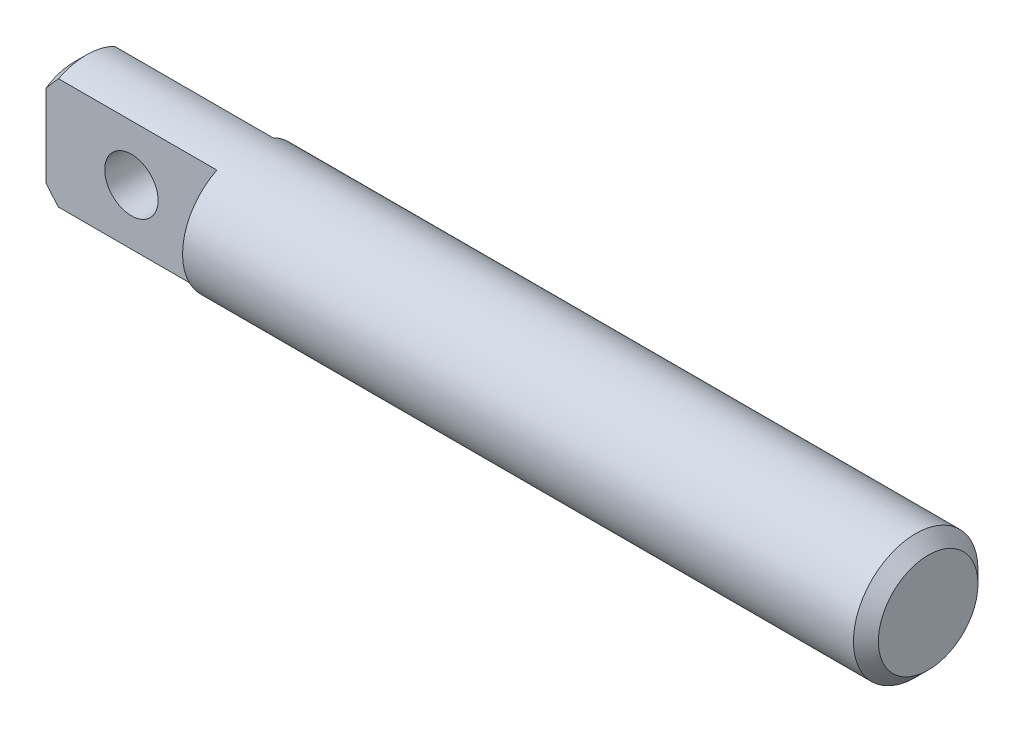
from build123d import *

# Parameters (mm, degrees)
SKETCH2_R           = 2.778125
EXTRUDE1_DEPTH      = 19.05
EXTRUDE1_DEPTH_BACK = 19.05
CHAMFER1_SIZE       = 0.555625
CUT_EXTRUDE1_DEPTH  = 7.62
SKETCH5_R           = 1.190625
CUT_EXTRUDE2_DEPTH  = 5.02828125


with BuildPart() as part:
    # Sketch2 → Extrude1 (new body, two sides)
    with BuildSketch(Plane(origin=(0, 0, 0), x_dir=(0, 0, -1), z_dir=(1, 0, 0))) as extrude1_sk:
        Circle(SKETCH2_R)
    extrude(amount=EXTRUDE1_DEPTH)
    extrude(extrude1_sk.sketch, amount=-EXTRUDE1_DEPTH_BACK)

    # Chamfer1
    chamfer1_edges = [part.edges().sort_by_distance(p)[0] for p in [
        (-19.05, 0, 2.778125),
        (19.05, 0, 2.778125),
    ]]
    chamfer(chamfer1_edges, length=CHAMFER1_SIZE)

    # Sketch3 → Cut-Extrude1 (cut)
    with BuildSketch(Plane.ZY.offset(19.05)):
        with BuildLine():
            Line((-3.175, 3.175), (-3.175, -3.175))
            Line((-3.175, -3.175), (-1.25015625, -3.175))
            Line((-1.25015625, -3.175), (-1.25015625, -1.837556965))
            ThreePointArc((-1.25015625, -1.837556965), (-2.2225, 0), (-1.25015625, 1.837556965))
            Line((-1.25015625, 1.837556965), (-1.25015625, 3.175))
            Line((-1.25015625, 3.175), (-3.175, 3.175))
        make_face()
        with BuildLine():
            Line((1.25015625, -1.837556965), (1.25015625, -3.175))
            Line((1.25015625, -3.175), (3.175, -3.175))
            Line((3.175, -3.175), (3.175, 3.175))
            Line((3.175, 3.175), (1.25015625, 3.175))
            Line((1.25015625, 3.175), (1.25015625, 1.837556965))
            ThreePointArc((1.25015625, 1.837556965), (1.964431026, 1.039479193), (2.2225, 0))
            ThreePointArc((2.2225, 0), (1.964431026, -1.039479193), (1.25015625, -1.837556965))
        make_face()
        with BuildLine():
            ThreePointArc((-1.25015625, 1.837556965), (-2.2225, 0), (-1.25015625, -1.837556965))
            Line((-1.25015625, -1.837556965), (-1.25015625, 1.837556965))
        make_face()
        with BuildLine():
            Line((1.25015625, 1.837556965), (1.25015625, -1.837556965))
            ThreePointArc((1.25015625, -1.837556965), (1.964431026, -1.039479193), (2.2225, 0))
            ThreePointArc((2.2225, 0), (1.964431026, 1.039479193), (1.25015625, 1.837556965))
        make_face()
    extrude(amount=-CUT_EXTRUDE1_DEPTH, mode=Mode.SUBTRACT)

    # Sketch5 → Cut-Extrude2 (cut, through all)
    with BuildSketch(Plane.XY.offset(1.25015625)):
        with Locations((-15.24, 0)):
            Circle(SKETCH5_R)
    extrude(amount=-CUT_EXTRUDE2_DEPTH, mode=Mode.SUBTRACT)


solid = part.part
